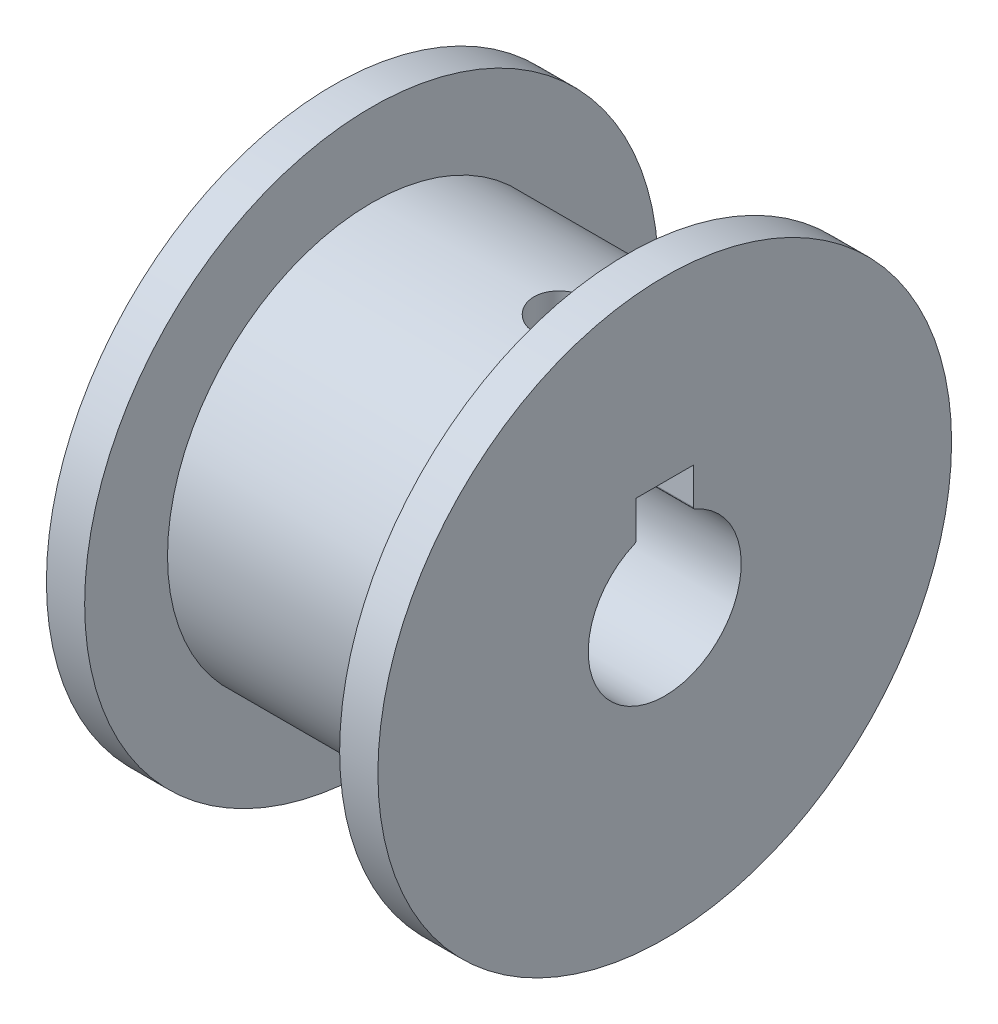
from build123d import *

# Parameters (mm, degrees)
SKETCH1_R               = 16
BOSS_EXTRUDE1_DEPTH     = 20
SKETCH3_R               = 22.5
BOSS_EXTRUDE2_DEPTH     = 3
SKETCH4_R               = 22.5
BOSS_EXTRUDE3_DEPTH     = 3
CUT_EXTRUDE2_DEPTH      = 3
CUT_EXTRUDE2_DEPTH_BACK = 25
SKETCH6_R               = 2.25
CUT_EXTRUDE3_DEPTH      = 10


with BuildPart() as part:
    # Sketch1 → Boss-Extrude1 (new body)
    with BuildSketch(Plane(origin=(0, 0, 0), x_dir=(0, 0, -1), z_dir=(1, 0, 0))):
        Circle(SKETCH1_R)
    extrude(amount=BOSS_EXTRUDE1_DEPTH)

    # Sketch3 → Boss-Extrude2 (add)
    with BuildSketch(Plane(origin=(20, 0, 0), x_dir=(0, 0, -1), z_dir=(1, 0, 0))):
        Circle(SKETCH3_R)
    extrude(amount=BOSS_EXTRUDE2_DEPTH)

    # Sketch4 → Boss-Extrude3 (add)
    with BuildSketch(Plane.ZY):
        Circle(SKETCH4_R)
    extrude(amount=BOSS_EXTRUDE3_DEPTH)

    # Sketch2 → Cut-Extrude2 (cut, two sides)
    with BuildSketch(Plane(origin=(20, 0, 0), x_dir=(0, 0, -1), z_dir=(1, 0, 0))) as cut_extrude2_sk:
        with BuildLine():
            Line((-2.25, 8.562148865), (2.25, 8.562148865))
            Line((2.25, 8.562148865), (2.25, 5.695392875))
            ThreePointArc((2.25, 5.695392875), (2.282957413, 5.585407539), (2.370967742, 5.511670524))
            ThreePointArc((2.370967742, 5.511670524), (0, -6), (-2.370967742, 5.511670524))
            ThreePointArc((-2.370967742, 5.511670524), (-2.282957413, 5.585407539), (-2.25, 5.695392875))
            Line((-2.25, 5.695392875), (-2.25, 8.562148865))
        make_face()
    extrude(amount=CUT_EXTRUDE2_DEPTH, mode=Mode.SUBTRACT)
    extrude(cut_extrude2_sk.sketch, amount=-CUT_EXTRUDE2_DEPTH_BACK, mode=Mode.SUBTRACT)

    # Sketch6 → Cut-Extrude3 (cut)
    with BuildSketch(Plane.XZ.offset(-8.562148865)):
        with Locations((15, 0)):
            Circle(SKETCH6_R)
    extrude(amount=-CUT_EXTRUDE3_DEPTH, mode=Mode.SUBTRACT)


solid = part.part
